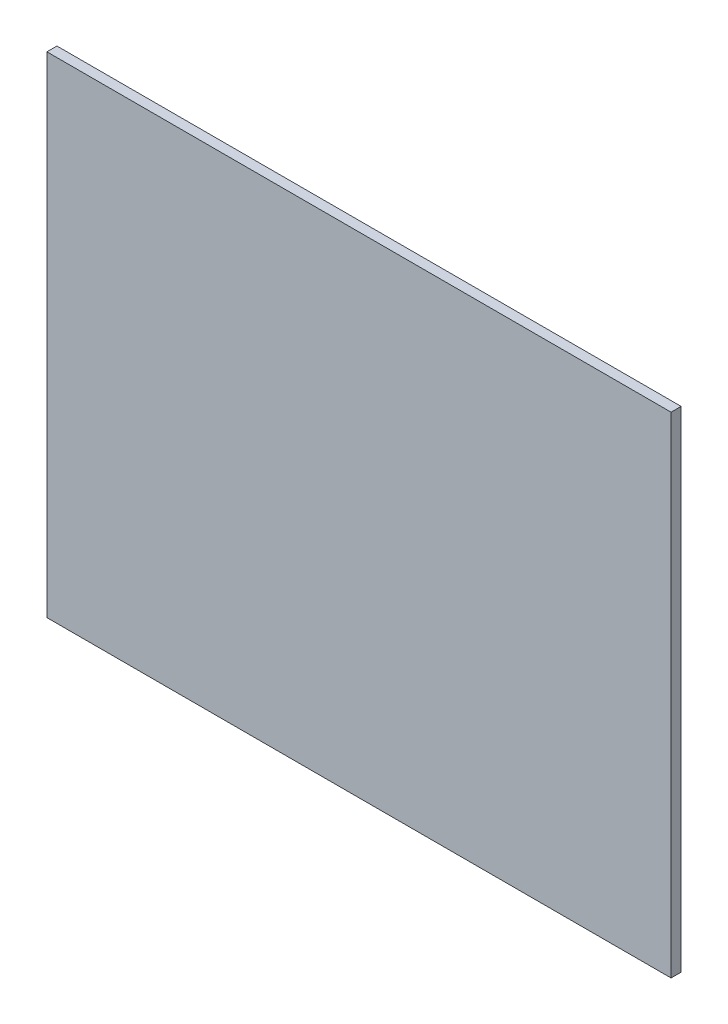
from build123d import *

# Parameters (mm, degrees)
SKETCH1_W           = 155.4
SKETCH1_H           = 122
BOSS_EXTRUDE1_DEPTH = 2.5


with BuildPart() as part:
    # Sketch1 → Boss-Extrude1 (new body)
    with BuildSketch(Plane.XY):
        with Locations((77.7, 61)):
            Rectangle(SKETCH1_W, SKETCH1_H)
    extrude(amount=BOSS_EXTRUDE1_DEPTH)


solid = part.part
